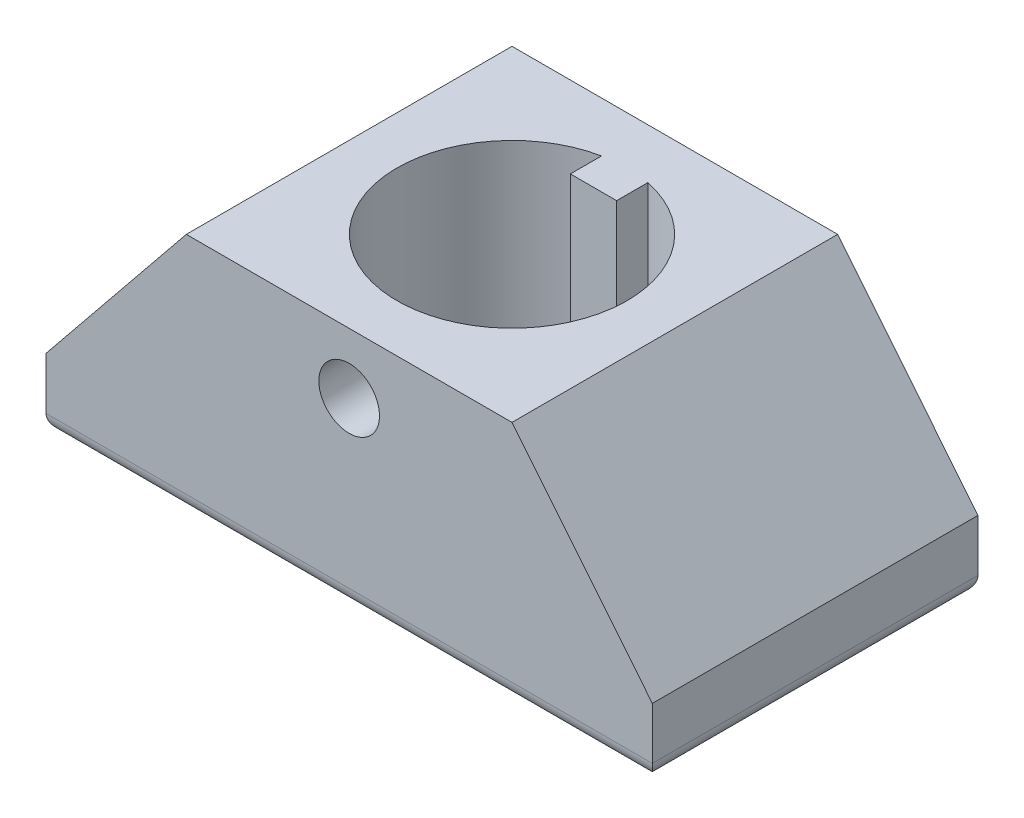
from build123d import *

# Parameters (mm, degrees)
SKETCH1_W           = 18.8
SKETCH1_H           = 18.8
BOSS_EXTRUDE1_DEPTH = 10
SKETCH5_R           = 1.75
CUT_EXTRUDE3_DEPTH  = 15
SKETCH6_W           = 35
SKETCH6_H           = 18.8
BOSS_EXTRUDE2_DEPTH = 4
BOSS_EXTRUDE3_DEPTH = 18.8
FILLET4_R           = 1
CUT_EXTRUDE4_DEPTH  = 4
FILLET5_R           = 0.5


with BuildPart() as part:
    # Sketch1 → Boss-Extrude1 (new body)
    with BuildSketch(Plane(origin=(0, 0, 0), x_dir=(1, 0, 0), z_dir=(0, 1, 0))):
        Rectangle(SKETCH1_W, SKETCH1_H)
        with BuildLine():
            Line((-1.335, 6.504411964), (-1.335, 4.704411964))
            Line((-1.335, 4.704411964), (1.335, 4.704411964))
            Line((1.335, 4.704411964), (1.335, 6.504411964))
            ThreePointArc((1.335, 6.504411964), (0, -6.64), (-1.335, 6.504411964))
        make_face(mode=Mode.SUBTRACT)
    extrude(amount=BOSS_EXTRUDE1_DEPTH)

    # Sketch5 → Cut-Extrude3 (cut)
    with BuildSketch(Plane.XY.offset(-4.704411964)):
        with Locations((-0.000110737, 6.5)):
            Circle(SKETCH5_R)
    extrude(amount=CUT_EXTRUDE3_DEPTH, mode=Mode.SUBTRACT)

    # Sketch6 → Boss-Extrude2 (add)
    with BuildSketch(Plane.XZ):
        Rectangle(SKETCH6_W, SKETCH6_H)
    extrude(amount=BOSS_EXTRUDE2_DEPTH)

    # Sketch7 → Boss-Extrude3 (add)
    with BuildSketch(Plane.XY.offset(9.4)):
        Polygon((-9.4, 10), (-9.4, 0), (-17.5, 0), align=None)
        Polygon((9.4, 0), (17.5, 0), (9.4, 10), align=None)
    extrude(amount=-BOSS_EXTRUDE3_DEPTH)

    # Fillet4
    fillet4_edges = [part.edges().sort_by_distance(p)[0] for p in [
        (-17.5, -4, 0),
        (0, -4, -9.4),
        (17.5, -4, 0),
        (0, -4, 9.4),
    ]]
    fillet(fillet4_edges, radius=FILLET4_R)

    # Sketch8 → Cut-Extrude4 (cut)
    with BuildSketch(Plane(origin=(0, 0, 0), x_dir=(1, 0, 0), z_dir=(0, 1, 0))):
        with BuildLine():
            Line((1.335, 4.704411964), (-1.335, 4.704411964))
            Line((-1.335, 4.704411964), (-1.335, 6.504411964))
            ThreePointArc((-1.335, 6.504411964), (0, -6.64), (1.335, 6.504411964))
            Line((1.335, 6.504411964), (1.335, 4.704411964))
        make_face()
    extrude(amount=-CUT_EXTRUDE4_DEPTH, mode=Mode.SUBTRACT)

    # Fillet5
    fillet5_edges = [part.edges().sort_by_distance(p)[0] for p in [
        (0, -4, 6.64),
        (-1.335, -4, -5.604411964),
        (0, -4, -4.704411964),
        (1.335, -4, -5.604411964),
    ]]
    fillet(fillet5_edges, radius=FILLET5_R)


solid = part.part
